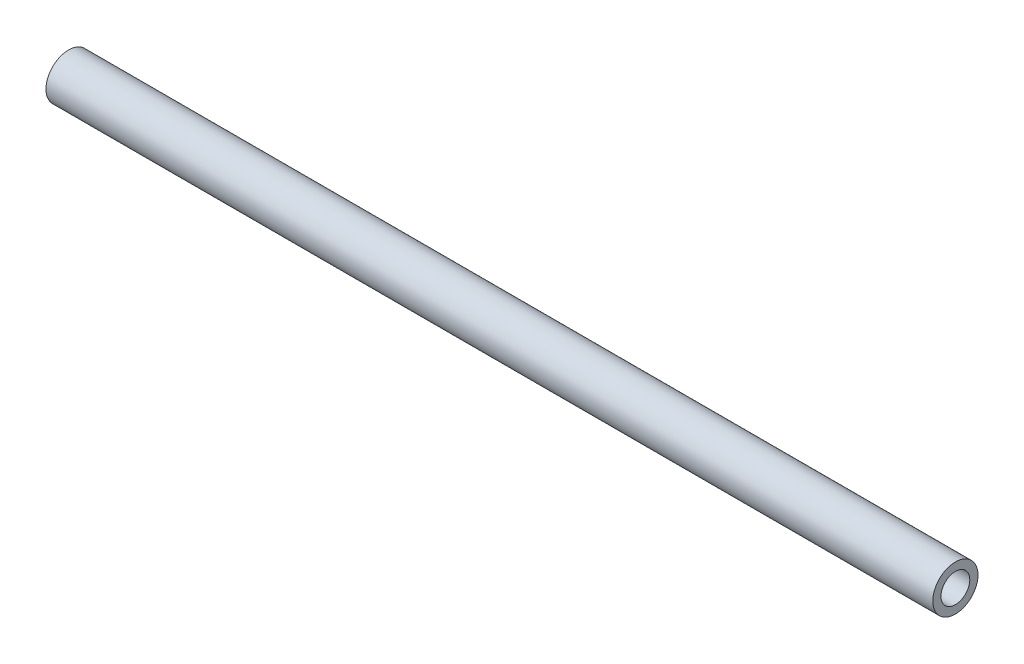
from build123d import *

# Parameters (mm, degrees)
SKETCH1_R           = 5.1
SKETCH1_R_2         = 3.25
BOSS_EXTRUDE1_DEPTH = 200


with BuildPart() as part:
    # Sketch1 → Boss-Extrude1 (new body)
    with BuildSketch(Plane(origin=(0, 0, 0), x_dir=(0, 0, -1), z_dir=(1, 0, 0))):
        Circle(SKETCH1_R)
        Circle(SKETCH1_R_2, mode=Mode.SUBTRACT)
    extrude(amount=BOSS_EXTRUDE1_DEPTH)


solid = part.part
